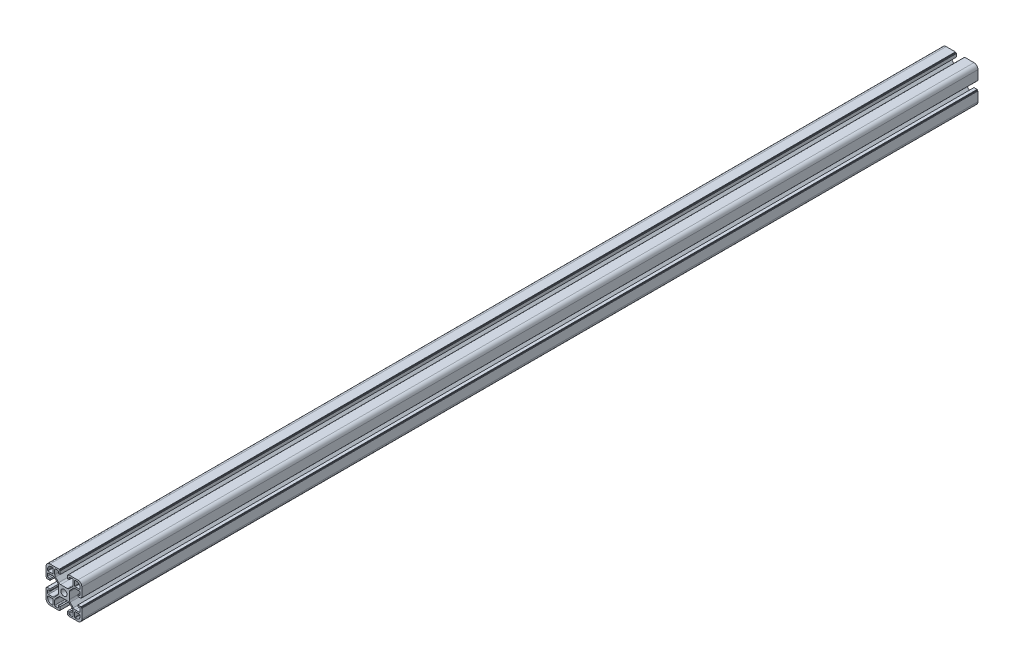
from build123d import *

# Parameters (mm, degrees)
BOSS_EXTRUDE1_DEPTH = 1000


with BuildPart() as part:
    # Sketch1 → Boss-Extrude1 (new body)
    with BuildSketch(Plane.XY):
        with BuildLine():
            Line((84.170223908, 31.720417041), (84.170223908, 42.120417041))
            Line((84.170223908, 42.120417041), (83.570223908, 42.120417041))
            ThreePointArc((83.570223908, 42.120417041), (83.428802552, 42.178995685), (83.370223908, 42.320417041))
            Line((83.370223908, 42.320417041), (83.370223908, 42.920417041))
            ThreePointArc((83.370223908, 42.920417041), (83.311645264, 43.061838398), (83.170223908, 43.120417041))
            Line((83.170223908, 43.120417041), (79.670223908, 43.120417041))
            Line((79.670223908, 43.120417041), (79.670223908, 41.320417041))
            Line((79.670223908, 41.320417041), (81.370223908, 41.320417041))
            ThreePointArc((81.370223908, 41.320417041), (82.077330689, 41.027523823), (82.370223908, 40.320417041))
            Line((82.370223908, 40.320417041), (82.370223908, 37.970417041))
            ThreePointArc((82.370223908, 37.970417041), (82.077330689, 37.26331026), (81.370223908, 36.970417041))
            Line((81.370223908, 36.970417041), (76.723524767, 36.970417041))
            ThreePointArc((76.723524767, 36.970417041), (75.57547447, 37.198778444), (74.602204423, 37.849096698))
            Line((74.602204423, 37.849096698), (71.048903564, 41.402397557))
            ThreePointArc((71.048903564, 41.402397557), (70.39858531, 42.375667603), (70.170223908, 43.5237179))
            Line((70.170223908, 43.5237179), (70.170223908, 50.917116183))
            ThreePointArc((70.170223908, 50.917116183), (70.39858531, 52.06516648), (71.048903564, 53.038436526))
            Line((71.048903564, 53.038436526), (74.602204423, 56.591737385))
            ThreePointArc((74.602204423, 56.591737385), (75.57547447, 57.242055639), (76.723524767, 57.470417041))
            Line((76.723524767, 57.470417041), (81.370223908, 57.470417041))
            ThreePointArc((81.370223908, 57.470417041), (82.077330689, 57.177523823), (82.370223908, 56.470417041))
            Line((82.370223908, 56.470417041), (82.370223908, 54.120417041))
            ThreePointArc((82.370223908, 54.120417041), (82.077330689, 53.41331026), (81.370223908, 53.120417041))
            Line((81.370223908, 53.120417041), (79.670223908, 53.120417041))
            Line((79.670223908, 53.120417041), (79.670223908, 51.320417041))
            Line((79.670223908, 51.320417041), (83.170223908, 51.320417041))
            ThreePointArc((83.170223908, 51.320417041), (83.311645264, 51.378995685), (83.370223908, 51.520417041))
            Line((83.370223908, 51.520417041), (83.370223908, 52.120417041))
            ThreePointArc((83.370223908, 52.120417041), (83.428802552, 52.261838398), (83.570223908, 52.320417041))
            Line((83.570223908, 52.320417041), (84.170223908, 52.320417041))
            Line((84.170223908, 52.320417041), (84.170223908, 62.720417041))
            ThreePointArc((84.170223908, 62.720417041), (82.852204423, 65.902397557), (79.670223908, 67.220417041))
            Line((79.670223908, 67.220417041), (69.470223908, 67.220417041))
            ThreePointArc((69.470223908, 67.220417041), (69.328802552, 67.161838398), (69.270223908, 67.020417041))
            Line((69.270223908, 67.020417041), (69.270223908, 66.620417041))
            ThreePointArc((69.270223908, 66.620417041), (69.211645264, 66.478995685), (69.070223908, 66.420417041))
            Line((69.070223908, 66.420417041), (68.470223908, 66.420417041))
            ThreePointArc((68.470223908, 66.420417041), (68.328802552, 66.361838398), (68.270223908, 66.220417041))
            Line((68.270223908, 66.220417041), (68.270223908, 62.720417041))
            Line((68.270223908, 62.720417041), (70.070223908, 62.720417041))
            Line((70.070223908, 62.720417041), (70.070223908, 64.420417041))
            ThreePointArc((70.070223908, 64.420417041), (70.363117127, 65.127523823), (71.070223908, 65.420417041))
            Line((71.070223908, 65.420417041), (73.420223908, 65.420417041))
            ThreePointArc((73.420223908, 65.420417041), (74.127330689, 65.127523823), (74.420223908, 64.420417041))
            Line((74.420223908, 64.420417041), (74.420223908, 59.7737179))
            ThreePointArc((74.420223908, 59.7737179), (74.191862505, 58.625667603), (73.541544251, 57.652397557))
            Line((73.541544251, 57.652397557), (69.988243393, 54.099096698))
            ThreePointArc((69.988243393, 54.099096698), (69.014973346, 53.448778444), (67.866923049, 53.220417041))
            Line((67.866923049, 53.220417041), (60.473524767, 53.220417041))
            ThreePointArc((60.473524767, 53.220417041), (59.32547447, 53.448778444), (58.352204423, 54.099096698))
            Line((58.352204423, 54.099096698), (54.798903564, 57.652397557))
            ThreePointArc((54.798903564, 57.652397557), (54.14858531, 58.625667603), (53.920223908, 59.7737179))
            Line((53.920223908, 59.7737179), (53.920223908, 64.420417041))
            ThreePointArc((53.920223908, 64.420417041), (54.213117127, 65.127523823), (54.920223908, 65.420417041))
            Line((54.920223908, 65.420417041), (57.270223908, 65.420417041))
            ThreePointArc((57.270223908, 65.420417041), (57.977330689, 65.127523823), (58.270223908, 64.420417041))
            Line((58.270223908, 64.420417041), (58.270223908, 62.720417041))
            Line((58.270223908, 62.720417041), (60.070223908, 62.720417041))
            Line((60.070223908, 62.720417041), (60.070223908, 66.220417041))
            ThreePointArc((60.070223908, 66.220417041), (60.011645264, 66.361838398), (59.870223908, 66.420417041))
            Line((59.870223908, 66.420417041), (59.270223908, 66.420417041))
            ThreePointArc((59.270223908, 66.420417041), (59.128802552, 66.478995685), (59.070223908, 66.620417041))
            Line((59.070223908, 66.620417041), (59.070223908, 67.020417041))
            ThreePointArc((59.070223908, 67.020417041), (59.011645264, 67.161838398), (58.870223908, 67.220417041))
            Line((58.870223908, 67.220417041), (48.670223908, 67.220417041))
            ThreePointArc((48.670223908, 67.220417041), (45.488243393, 65.902397557), (44.170223908, 62.720417041))
            Line((44.170223908, 62.720417041), (44.170223908, 52.320417041))
            Line((44.170223908, 52.320417041), (44.770223908, 52.320417041))
            ThreePointArc((44.770223908, 52.320417041), (44.911645264, 52.261838398), (44.970223908, 52.120417041))
            Line((44.970223908, 52.120417041), (44.970223908, 51.520417041))
            ThreePointArc((44.970223908, 51.520417041), (45.028802552, 51.378995685), (45.170223908, 51.320417041))
            Line((45.170223908, 51.320417041), (48.670223908, 51.320417041))
            Line((48.670223908, 51.320417041), (48.670223908, 53.120417041))
            Line((48.670223908, 53.120417041), (46.970223908, 53.120417041))
            ThreePointArc((46.970223908, 53.120417041), (46.263117127, 53.41331026), (45.970223908, 54.120417041))
            Line((45.970223908, 54.120417041), (45.970223908, 56.470417041))
            ThreePointArc((45.970223908, 56.470417041), (46.263117127, 57.177523823), (46.970223908, 57.470417041))
            Line((46.970223908, 57.470417041), (51.616923049, 57.470417041))
            ThreePointArc((51.616923049, 57.470417041), (52.764973346, 57.242055639), (53.738243393, 56.591737385))
            Line((53.738243393, 56.591737385), (57.291544251, 53.038436526))
            ThreePointArc((57.291544251, 53.038436526), (57.941862505, 52.06516648), (58.170223908, 50.917116183))
            Line((58.170223908, 50.917116183), (58.170223908, 43.5237179))
            ThreePointArc((58.170223908, 43.5237179), (57.941862505, 42.375667603), (57.291544251, 41.402397557))
            Line((57.291544251, 41.402397557), (53.738243393, 37.849096698))
            ThreePointArc((53.738243393, 37.849096698), (52.764973346, 37.198778444), (51.616923049, 36.970417041))
            Line((51.616923049, 36.970417041), (46.970223908, 36.970417041))
            ThreePointArc((46.970223908, 36.970417041), (46.263117127, 37.26331026), (45.970223908, 37.970417041))
            Line((45.970223908, 37.970417041), (45.970223908, 40.320417041))
            ThreePointArc((45.970223908, 40.320417041), (46.263117127, 41.027523823), (46.970223908, 41.320417041))
            Line((46.970223908, 41.320417041), (48.670223908, 41.320417041))
            Line((48.670223908, 41.320417041), (48.670223908, 43.120417041))
            Line((48.670223908, 43.120417041), (45.170223908, 43.120417041))
            ThreePointArc((45.170223908, 43.120417041), (45.028802552, 43.061838398), (44.970223908, 42.920417041))
            Line((44.970223908, 42.920417041), (44.970223908, 42.320417041))
            ThreePointArc((44.970223908, 42.320417041), (44.911645264, 42.178995685), (44.770223908, 42.120417041))
            Line((44.770223908, 42.120417041), (44.170223908, 42.120417041))
            Line((44.170223908, 42.120417041), (44.170223908, 31.720417041))
            ThreePointArc((44.170223908, 31.720417041), (45.488243393, 28.538436526), (48.670223908, 27.220417041))
            Line((48.670223908, 27.220417041), (59.070223908, 27.220417041))
            Line((59.070223908, 27.220417041), (59.070223908, 27.820417041))
            ThreePointArc((59.070223908, 27.820417041), (59.128802552, 27.961838398), (59.270223908, 28.020417041))
            Line((59.270223908, 28.020417041), (59.870223908, 28.020417041))
            ThreePointArc((59.870223908, 28.020417041), (60.011645264, 28.078995685), (60.070223908, 28.220417041))
            Line((60.070223908, 28.220417041), (60.070223908, 31.720417041))
            Line((60.070223908, 31.720417041), (58.270223908, 31.720417041))
            Line((58.270223908, 31.720417041), (58.270223908, 30.020417041))
            ThreePointArc((58.270223908, 30.020417041), (57.977330689, 29.31331026), (57.270223908, 29.020417041))
            Line((57.270223908, 29.020417041), (54.920223908, 29.020417041))
            ThreePointArc((54.920223908, 29.020417041), (54.213117127, 29.31331026), (53.920223908, 30.020417041))
            Line((53.920223908, 30.020417041), (53.920223908, 34.667116183))
            ThreePointArc((53.920223908, 34.667116183), (54.14858531, 35.81516648), (54.798903564, 36.788436526))
            Line((54.798903564, 36.788436526), (58.352204423, 40.341737385))
            ThreePointArc((58.352204423, 40.341737385), (59.32547447, 40.992055639), (60.473524767, 41.220417041))
            Line((60.473524767, 41.220417041), (67.866923049, 41.220417041))
            ThreePointArc((67.866923049, 41.220417041), (69.014973346, 40.992055639), (69.988243393, 40.341737385))
            Line((69.988243393, 40.341737385), (73.541544251, 36.788436526))
            ThreePointArc((73.541544251, 36.788436526), (74.191862505, 35.81516648), (74.420223908, 34.667116183))
            Line((74.420223908, 34.667116183), (74.420223908, 30.020417041))
            ThreePointArc((74.420223908, 30.020417041), (74.127330689, 29.31331026), (73.420223908, 29.020417041))
            Line((73.420223908, 29.020417041), (71.070223908, 29.020417041))
            ThreePointArc((71.070223908, 29.020417041), (70.363117127, 29.31331026), (70.070223908, 30.020417041))
            Line((70.070223908, 30.020417041), (70.070223908, 31.720417041))
            Line((70.070223908, 31.720417041), (68.270223908, 31.720417041))
            Line((68.270223908, 31.720417041), (68.270223908, 28.220417041))
            ThreePointArc((68.270223908, 28.220417041), (68.328802552, 28.078995685), (68.470223908, 28.020417041))
            Line((68.470223908, 28.020417041), (69.070223908, 28.020417041))
            ThreePointArc((69.070223908, 28.020417041), (69.211645264, 27.961838398), (69.270223908, 27.820417041))
            Line((69.270223908, 27.820417041), (69.270223908, 27.220417041))
            Line((69.270223908, 27.220417041), (79.670223908, 27.220417041))
            ThreePointArc((79.670223908, 27.220417041), (82.852204423, 28.538436526), (84.170223908, 31.720417041))
        make_face()
        with BuildLine():
            Line((82.370223908, 34.670417041), (82.370223908, 33.520417041))
            ThreePointArc((82.370223908, 33.520417041), (81.052204423, 30.338436526), (77.870223908, 29.020417041))
            Line((77.870223908, 29.020417041), (76.720223908, 29.020417041))
            ThreePointArc((76.720223908, 29.020417041), (76.366670517, 29.166863651), (76.220223908, 29.520417041))
            Line((76.220223908, 29.520417041), (76.220223908, 34.670417041))
            ThreePointArc((76.220223908, 34.670417041), (76.366670517, 35.023970432), (76.720223908, 35.170417041))
            Line((76.720223908, 35.170417041), (81.870223908, 35.170417041))
            ThreePointArc((81.870223908, 35.170417041), (82.223777298, 35.023970432), (82.370223908, 34.670417041))
        make_face(mode=Mode.SUBTRACT)
        with BuildLine():
            Line((51.620223908, 29.020417041), (50.470223908, 29.020417041))
            ThreePointArc((50.470223908, 29.020417041), (47.288243393, 30.338436526), (45.970223908, 33.520417041))
            Line((45.970223908, 33.520417041), (45.970223908, 34.670417041))
            ThreePointArc((45.970223908, 34.670417041), (46.116670517, 35.023970432), (46.470223908, 35.170417041))
            Line((46.470223908, 35.170417041), (51.620223908, 35.170417041))
            ThreePointArc((51.620223908, 35.170417041), (51.973777298, 35.023970432), (52.120223908, 34.670417041))
            Line((52.120223908, 34.670417041), (52.120223908, 29.520417041))
            ThreePointArc((52.120223908, 29.520417041), (51.973777298, 29.166863651), (51.620223908, 29.020417041))
        make_face(mode=Mode.SUBTRACT)
        with BuildLine():
            Line((45.970223908, 59.770417041), (45.970223908, 60.920417041))
            ThreePointArc((45.970223908, 60.920417041), (47.288243393, 64.102397557), (50.470223908, 65.420417041))
            Line((50.470223908, 65.420417041), (51.620223908, 65.420417041))
            ThreePointArc((51.620223908, 65.420417041), (51.973777298, 65.273970432), (52.120223908, 64.920417041))
            Line((52.120223908, 64.920417041), (52.120223908, 59.770417041))
            ThreePointArc((52.120223908, 59.770417041), (51.973777298, 59.416863651), (51.620223908, 59.270417041))
            Line((51.620223908, 59.270417041), (46.470223908, 59.270417041))
            ThreePointArc((46.470223908, 59.270417041), (46.116670517, 59.416863651), (45.970223908, 59.770417041))
        make_face(mode=Mode.SUBTRACT)
        with BuildLine():
            Line((76.720223908, 65.420417041), (77.870223908, 65.420417041))
            ThreePointArc((77.870223908, 65.420417041), (81.052204423, 64.102397557), (82.370223908, 60.920417041))
            Line((82.370223908, 60.920417041), (82.370223908, 59.770417041))
            ThreePointArc((82.370223908, 59.770417041), (82.223777298, 59.416863651), (81.870223908, 59.270417041))
            Line((81.870223908, 59.270417041), (76.720223908, 59.270417041))
            ThreePointArc((76.720223908, 59.270417041), (76.366670517, 59.416863651), (76.220223908, 59.770417041))
            Line((76.220223908, 59.770417041), (76.220223908, 64.920417041))
            ThreePointArc((76.220223908, 64.920417041), (76.366670517, 65.273970432), (76.720223908, 65.420417041))
        make_face(mode=Mode.SUBTRACT)
        with BuildLine():
            ThreePointArc((60.770223908, 47.220417041), (64.170223908, 43.820417041), (67.570223908, 47.220417041))
            ThreePointArc((67.570223908, 47.220417041), (64.170223908, 50.620417041), (60.770223908, 47.220417041))
        make_face(mode=Mode.SUBTRACT)
    extrude(amount=BOSS_EXTRUDE1_DEPTH)


solid = part.part
